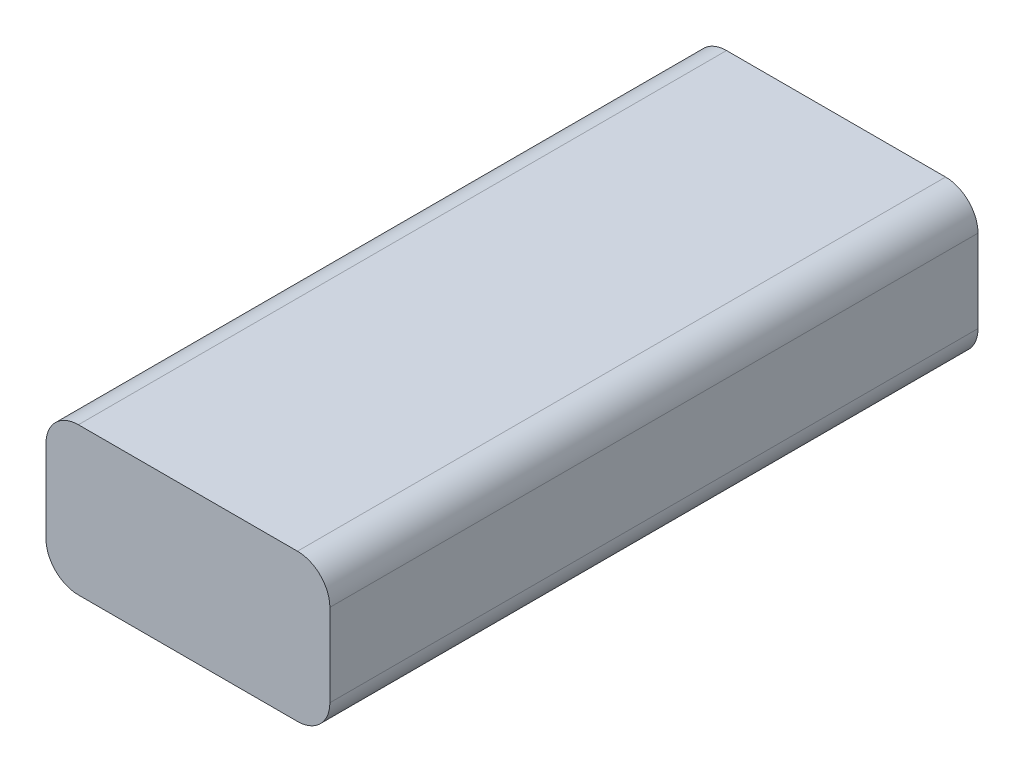
from build123d import *

# Parameters (mm, degrees)
BOSS_EXTRUDE1_DEPTH = 25.4


with BuildPart() as part:
    # Sketch1 → Boss-Extrude1 (new body)
    with BuildSketch(Plane.XY):
        with BuildLine():
            Line((-3.267030461, 4.202605611), (5.318169539, 4.202605611))
            ThreePointArc((5.318169539, 4.202605611), (6.216195151, 3.830631223), (6.588169539, 2.932605611))
            Line((6.588169539, 2.932605611), (6.588169539, -0.305894389))
            ThreePointArc((6.588169539, -0.305894389), (6.216195151, -1.203920001), (5.318169539, -1.575894389))
            Line((5.318169539, -1.575894389), (-3.267030461, -1.575894389))
            ThreePointArc((-3.267030461, -1.575894389), (-4.165056073, -1.203920001), (-4.537030461, -0.305894389))
            Line((-4.537030461, -0.305894389), (-4.537030461, 2.932605611))
            ThreePointArc((-4.537030461, 2.932605611), (-4.165056073, 3.830631223), (-3.267030461, 4.202605611))
        make_face()
    extrude(amount=BOSS_EXTRUDE1_DEPTH)


solid = part.part
